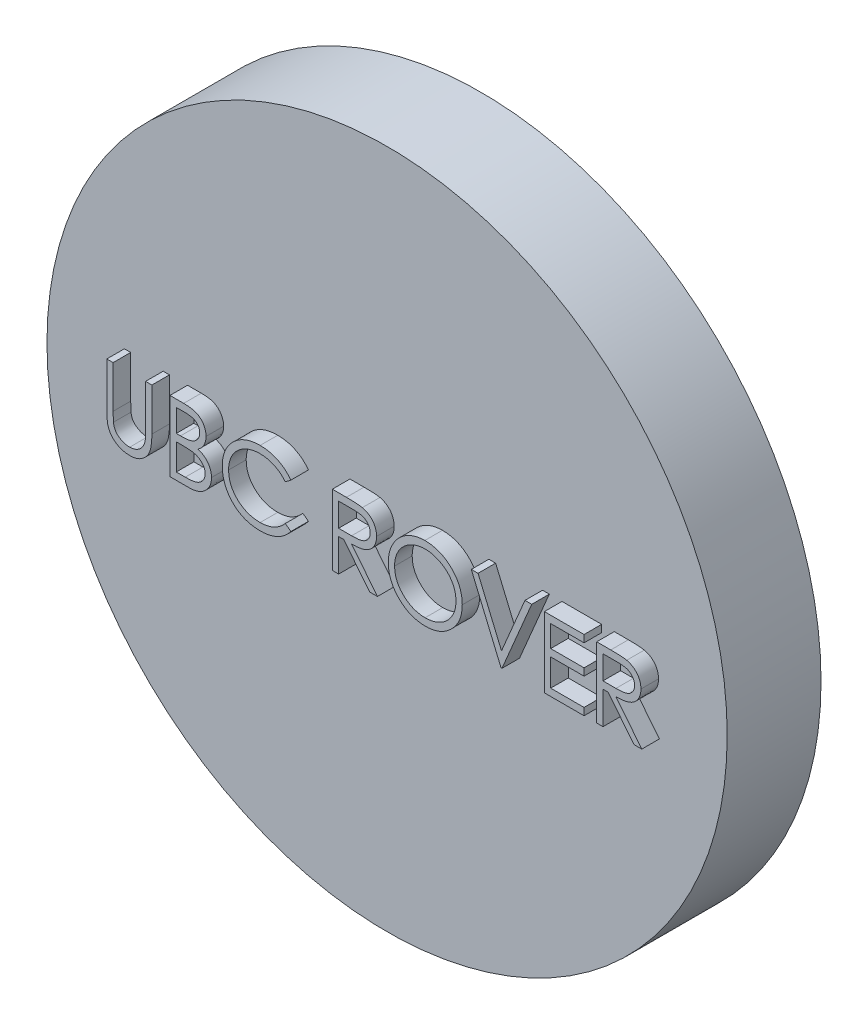
from build123d import *

# Parameters (mm, degrees)
SKETCH1_R           = 29
PLATE_DEPTH         = 8
BOSS_EXTRUDE4_DEPTH = 1.5


with BuildPart() as part:
    # Sketch1 → Plate (new body)
    with BuildSketch(Plane.XY):
        Circle(SKETCH1_R)
    extrude(amount=PLATE_DEPTH)

    # Sketch4 → Boss-Extrude4 (add)
    with BuildSketch(Plane.XY.offset(8)):
        with BuildLine():
            Line((-22.398192779, 2.851925), (-21.85973124, 2.851925))
            Line((-21.85973124, 2.851925), (-21.85973124, -0.743026923))
            add(Edge.make_bspline(
                [(-21.85973124, -0.743026923), (-21.859811373, -0.793908184), (-21.859963438, -0.890464146), (-21.8589477, -1.027895518), (-21.856103068, -1.150076877), (-21.854309652, -1.257479187), (-21.850319937, -1.349609611), (-21.847066143, -1.426967286), (-21.842882331, -1.489185919), (-21.83785413, -1.525496078), (-21.835692779, -1.541103846)],
                knots=[0, 0, 0, 0, 0.000152644, 0.000289669, 0.000412288, 0.000519287, 0.000611905, 0.000688912, 0.000751597, 0.000798856, 0.000798856, 0.000798856, 0.000798856], degree=3))
            add(Edge.make_bspline(
                [(-21.835692779, -1.541103846), (-21.826817135, -1.597412583), (-21.809565958, -1.706857262), (-21.765600739, -1.862700031), (-21.704199309, -2.003153959), (-21.631439807, -2.132601887), (-21.535555331, -2.24744079), (-21.420692127, -2.353232195), (-21.281530238, -2.445755288), (-21.126797772, -2.53035668), (-20.960023079, -2.598353964), (-20.789603765, -2.64977116), (-20.618101515, -2.681106417), (-20.503285232, -2.684734769), (-20.446269702, -2.686536538)],
                knots=[0, 0, 0, 0, 0.000170931, 0.000332231, 0.000484054, 0.000630007, 0.000776055, 0.000930884, 0.001096906, 0.001275996, 0.001459245, 0.001636075, 0.001809373, 0.001980317, 0.001980317, 0.001980317, 0.001980317], degree=3))
            add(Edge.make_bspline(
                [(-20.446269702, -2.686536538), (-20.397320432, -2.684695652), (-20.299704612, -2.681024512), (-20.154665017, -2.658290631), (-20.013407687, -2.617318232), (-19.875235093, -2.564450075), (-19.74571912, -2.494597062), (-19.624787505, -2.413904194), (-19.516849332, -2.319256978), (-19.418349907, -2.21451353), (-19.332575732, -2.096331016), (-19.258225203, -1.967282779), (-19.197323609, -1.825426756), (-19.167248995, -1.725733461), (-19.151798548, -1.674517308)],
                knots=[0, 0, 0, 0, 0.000146876, 0.000292903, 0.000439015, 0.000587441, 0.000735844, 0.000879522, 0.001022667, 0.00116554, 0.001310021, 0.001459697, 0.001611521, 0.001771922, 0.001771922, 0.001771922, 0.001771922], degree=3))
            add(Edge.make_bspline(
                [(-19.151798548, -1.674517308), (-19.146655476, -1.653348323), (-19.135194639, -1.606175294), (-19.124485419, -1.526424511), (-19.113331375, -1.432328458), (-19.105592113, -1.323211065), (-19.098047163, -1.199437969), (-19.093533324, -1.060364385), (-19.091446982, -0.906495309), (-19.090825244, -0.799117317), (-19.090500471, -0.743026923)],
                knots=[0, 0, 0, 0, 6.5314e-05, 0.000145547, 0.000241113, 0.000349613, 0.00047362, 0.000613126, 0.000766991, 0.000935265, 0.000935265, 0.000935265, 0.000935265], degree=3))
            Line((-19.090500471, -0.743026923), (-19.090500471, 2.851925))
            Line((-19.090500471, 2.851925), (-18.552038932, 2.851925))
            Line((-18.552038932, 2.851925), (-18.552038932, -0.771873077))
            add(Edge.make_bspline(
                [(-18.552038932, -0.771873077), (-18.552474567, -0.837184584), (-18.553324735, -0.96464396), (-18.560697152, -1.151417718), (-18.572452009, -1.328594258), (-18.58906016, -1.496197395), (-18.611066451, -1.653627382), (-18.635538258, -1.802264127), (-18.666703172, -1.941040686), (-18.703103288, -2.071039117), (-18.744715085, -2.194785711), (-18.798614196, -2.31222905), (-18.85934191, -2.42693945), (-18.931367029, -2.537181922), (-19.012300828, -2.643444585), (-19.103932281, -2.745082999), (-19.203230842, -2.843721364), (-19.31184723, -2.936829477), (-19.427990988, -3.022215781), (-19.55131663, -3.097297674), (-19.680876806, -3.160766732), (-19.816334737, -3.213011174), (-19.957748228, -3.252293344), (-20.105120844, -3.28156504), (-20.258788033, -3.29819755), (-20.363298872, -3.30066943), (-20.416221625, -3.301921154)],
                knots=[0, 0, 0, 0, 0.000195928, 0.000382366, 0.000560656, 0.000728569, 0.0008875, 0.001037476, 0.001180358, 0.001313923, 0.001442399, 0.001571515, 0.001701111, 0.001831463, 0.001966084, 0.002101432, 0.002241667, 0.002385722, 0.002530203, 0.00267367, 0.002818266, 0.002962462, 0.003108574, 0.003258019, 0.003412782, 0.00357155, 0.00357155, 0.00357155, 0.00357155], degree=3))
            add(Edge.make_bspline(
                [(-20.416221625, -3.301921154), (-20.473940086, -3.300575842), (-20.587183502, -3.297936345), (-20.75404876, -3.28281163), (-20.914015953, -3.254322954), (-21.0687746, -3.218048765), (-21.216217738, -3.168019501), (-21.358320785, -3.109565573), (-21.492649953, -3.037775984), (-21.621384459, -2.957901596), (-21.741084041, -2.868030788), (-21.850965304, -2.770076204), (-21.951209653, -2.665606985), (-22.040127418, -2.553492072), (-22.119191792, -2.434603432), (-22.187300729, -2.308604735), (-22.245780576, -2.175544765), (-22.275963263, -2.083053564), (-22.291221625, -2.036296154)],
                knots=[0, 0, 0, 0, 0.000173181, 0.000339781, 0.000502009, 0.000660303, 0.000816137, 0.000968596, 0.001120747, 0.001272485, 0.001422726, 0.001569153, 0.001713674, 0.001856521, 0.001997863, 0.002141462, 0.002285712, 0.002433192, 0.002433192, 0.002433192, 0.002433192], degree=3))
            add(Edge.make_bspline(
                [(-22.291221625, -2.036296154), (-22.300096753, -2.004354598), (-22.319347104, -1.935072651), (-22.3399619, -1.820410099), (-22.357291754, -1.688384526), (-22.373586997, -1.538986894), (-22.383202353, -1.372101409), (-22.391632248, -1.18780041), (-22.398252166, -0.985861047), (-22.398213128, -0.845196163), (-22.398192779, -0.771873077)],
                knots=[0, 0, 0, 0, 9.9411e-05, 0.000215626, 0.000349061, 0.000498916, 0.000666333, 0.00085042, 0.001052432, 0.001272388, 0.001272388, 0.001272388, 0.001272388], degree=3))
            Line((-22.398192779, -0.771873077), (-22.398192779, 2.851925))
        make_face()
        with BuildLine():
            Line((-17.013577394, 2.851925), (-15.842904317, 2.851925))
            add(Edge.make_bspline(
                [(-15.842904317, 2.851925), (-15.785598354, 2.851623714), (-15.674525137, 2.851039746), (-15.513006094, 2.841982949), (-15.361722418, 2.829633801), (-15.220630237, 2.810039356), (-15.089794747, 2.78639631), (-14.968821655, 2.757764625), (-14.858095645, 2.723433287), (-14.725902383, 2.668839662), (-14.57518125, 2.587714231), (-14.411984005, 2.467836691), (-14.272433881, 2.321209611), (-14.15211448, 2.155810773), (-14.056455417, 1.973863736), (-13.987250908, 1.779705127), (-13.943437407, 1.575839283), (-13.93893152, 1.43587955), (-13.936654317, 1.365146154)],
                knots=[0, 0, 0, 0, 0.000171892, 0.000333169, 0.000485187, 0.000627121, 0.000760318, 0.000883923, 0.000999864, 0.001107669, 0.001312564, 0.001511844, 0.001712447, 0.001917282, 0.002123733, 0.002326748, 0.002534183, 0.002746134, 0.002746134, 0.002746134, 0.002746134], degree=3))
            add(Edge.make_bspline(
                [(-13.936654317, 1.365146154), (-13.938528406, 1.29888463), (-13.942211167, 1.168674486), (-13.977427326, 0.978227442), (-14.0325599, 0.796939638), (-14.10919747, 0.625472692), (-14.208800892, 0.467700783), (-14.326843724, 0.322351185), (-14.4692611, 0.195577944), (-14.575963797, 0.124704397), (-14.630163932, 0.088703846)],
                knots=[0, 0, 0, 0, 0.000198612, 0.000390292, 0.000578867, 0.000766074, 0.000951829, 0.001137116, 0.001326066, 0.001521126, 0.001521126, 0.001521126, 0.001521126], degree=3))
            add(Edge.make_bspline(
                [(-14.630163932, 0.088703846), (-14.562003199, 0.062535277), (-14.431594833, 0.01246832), (-14.252133097, -0.076049618), (-14.097513363, -0.172327521), (-13.966546827, -0.277467836), (-13.854539418, -0.390797226), (-13.756734376, -0.513977422), (-13.673280591, -0.648615292), (-13.601772722, -0.793307067), (-13.545974855, -0.946575299), (-13.50418759, -1.106982343), (-13.480243392, -1.273953009), (-13.476836007, -1.387585088), (-13.475115856, -1.44495)],
                knots=[0, 0, 0, 0, 0.000218951, 0.000418908, 0.000599313, 0.000764309, 0.000921541, 0.001076402, 0.001235147, 0.001395868, 0.001559758, 0.00172359, 0.001892378, 0.002064459, 0.002064459, 0.002064459, 0.002064459], degree=3))
            add(Edge.make_bspline(
                [(-13.475115856, -1.44495), (-13.476790449, -1.503521781), (-13.480085258, -1.6187634), (-13.504393781, -1.788057917), (-13.54555225, -1.94984354), (-13.602245644, -2.10516671), (-13.676238183, -2.25372694), (-13.766286122, -2.395692536), (-13.873654517, -2.529637103), (-13.993762292, -2.657049028), (-14.129640256, -2.771610949), (-14.276238693, -2.873637875), (-14.435403813, -2.95754541), (-14.604521517, -3.028030018), (-14.785488916, -3.08187093), (-14.977493385, -3.119538199), (-15.180369331, -3.144918263), (-15.319586048, -3.1470049), (-15.39098124, -3.148075)],
                knots=[0, 0, 0, 0, 0.000175682, 0.00034566, 0.000511821, 0.000675711, 0.000840729, 0.001008779, 0.001179033, 0.001355011, 0.001533224, 0.001711255, 0.001889776, 0.002071914, 0.002260141, 0.002455078, 0.002658427, 0.002872491, 0.002872491, 0.002872491, 0.002872491], degree=3))
            Line((-15.39098124, -3.148075), (-17.013577394, -3.148075))
            Line((-17.013577394, -3.148075), (-17.013577394, 2.851925))
        make_face()
        with BuildLine():
            Line((-16.475115856, 2.236540385), (-16.475115856, 0.313463462))
            Line((-16.475115856, 0.313463462), (-16.113337009, 0.313463462))
            add(Edge.make_bspline(
                [(-16.113337009, 0.313463462), (-16.06045336, 0.314149044), (-15.958271373, 0.315473729), (-15.810294407, 0.319268329), (-15.672937233, 0.329893547), (-15.546436948, 0.34051571), (-15.430992758, 0.357786432), (-15.326860424, 0.378344357), (-15.232405687, 0.40008648), (-15.123480752, 0.437062743), (-14.999927126, 0.491710186), (-14.868213233, 0.576519048), (-14.752096999, 0.677532225), (-14.654044677, 0.794088159), (-14.573796442, 0.922430192), (-14.518058645, 1.060510559), (-14.480263301, 1.204887928), (-14.476849247, 1.304004933), (-14.475115856, 1.354328846)],
                knots=[0, 0, 0, 0, 0.000158672, 0.000306587, 0.000443943, 0.000571912, 0.000687328, 0.000793873, 0.000890365, 0.000977783, 0.00113863, 0.001294329, 0.001445952, 0.001598616, 0.001749719, 0.001897926, 0.002043974, 0.002194603, 0.002194603, 0.002194603, 0.002194603], degree=3))
            add(Edge.make_bspline(
                [(-14.475115856, 1.354328846), (-14.476017879, 1.387630169), (-14.477787296, 1.452954349), (-14.492278672, 1.548181814), (-14.516908799, 1.637742532), (-14.54854473, 1.722863864), (-14.592753911, 1.800884179), (-14.644805562, 1.874501086), (-14.707695317, 1.941207575), (-14.779279282, 2.003555286), (-14.861579778, 2.05883162), (-14.954547707, 2.107244356), (-15.059440868, 2.146228545), (-15.174491476, 2.180370521), (-15.301470483, 2.204350453), (-15.438912575, 2.224327689), (-15.587943522, 2.234498104), (-15.691049412, 2.23584444), (-15.744346625, 2.236540385)],
                knots=[0, 0, 0, 0, 9.9875e-05, 0.000195916, 0.00028805, 0.000378226, 0.000467533, 0.000556256, 0.000648107, 0.000741841, 0.000840516, 0.000944807, 0.001055521, 0.001175713, 0.001304415, 0.001442777, 0.001592207, 0.001752104, 0.001752104, 0.001752104, 0.001752104], degree=3))
            Line((-15.744346625, 2.236540385), (-16.475115856, 2.236540385))
        make_face(mode=Mode.SUBTRACT)
        with BuildLine():
            Line((-16.475115856, -0.301921154), (-16.475115856, -2.532690385))
            Line((-16.475115856, -2.532690385), (-15.708288932, -2.532690385))
            add(Edge.make_bspline(
                [(-15.708288932, -2.532690385), (-15.653399345, -2.532032532), (-15.547606902, -2.530764608), (-15.394861936, -2.526625371), (-15.253290901, -2.517210041), (-15.123539811, -2.502388585), (-15.004207607, -2.486311243), (-14.89672583, -2.464691905), (-14.800223213, -2.439922258), (-14.688324399, -2.401635106), (-14.562318385, -2.342155441), (-14.426528346, -2.25247391), (-14.305797686, -2.145633954), (-14.203274384, -2.021980958), (-14.119252118, -1.887527255), (-14.058128481, -1.744992369), (-14.02042987, -1.596731465), (-14.015866151, -1.495645672), (-14.013577394, -1.44495)],
                knots=[0, 0, 0, 0, 0.000164681, 0.000317401, 0.000458354, 0.000590155, 0.00070914, 0.000819455, 0.000918867, 0.001007809, 0.001173944, 0.001335288, 0.001494492, 0.00165577, 0.001815535, 0.001968463, 0.002119466, 0.002271384, 0.002271384, 0.002271384, 0.002271384], degree=3))
            add(Edge.make_bspline(
                [(-14.013577394, -1.44495), (-14.014050716, -1.413247131), (-14.014989724, -1.350352762), (-14.029150779, -1.257925643), (-14.049745984, -1.168395575), (-14.076371299, -1.081519448), (-14.115147528, -0.998867946), (-14.160415891, -0.918806415), (-14.21349258, -0.841229022), (-14.296196864, -0.743150873), (-14.416491695, -0.63015028), (-14.587417596, -0.519514561), (-14.781770106, -0.430289749), (-14.922731523, -0.392404933), (-14.995548548, -0.372834615)],
                knots=[0, 0, 0, 0, 9.502e-05, 0.000188508, 0.000279767, 0.000370614, 0.000460437, 0.000553016, 0.000646365, 0.000741931, 0.000937523, 0.001138873, 0.001350251, 0.001576123, 0.001576123, 0.001576123, 0.001576123], degree=3))
            add(Edge.make_bspline(
                [(-14.995548548, -0.372834615), (-15.024741284, -0.366911614), (-15.088037156, -0.354069326), (-15.191250151, -0.340513263), (-15.309083069, -0.328436018), (-15.441808002, -0.319502605), (-15.589592872, -0.31026853), (-15.752753304, -0.306677408), (-15.930622986, -0.302392962), (-16.054038482, -0.302082446), (-16.118144702, -0.301921154)],
                knots=[0, 0, 0, 0, 8.9339e-05, 0.000193706, 0.000312106, 0.000444667, 0.000592743, 0.000756275, 0.000934196, 0.001126508, 0.001126508, 0.001126508, 0.001126508], degree=3))
            Line((-16.118144702, -0.301921154), (-16.475115856, -0.301921154))
        make_face(mode=Mode.SUBTRACT)
        with BuildLine():
            Line((-6.705885086, 1.750963462), (-7.177038932, 1.390386538))
            add(Edge.make_bspline(
                [(-7.177038932, 1.390386538), (-7.210649027, 1.430442487), (-7.277416078, 1.510014342), (-7.384831854, 1.621750704), (-7.496777528, 1.72643401), (-7.613210307, 1.824562946), (-7.73622594, 1.912705973), (-7.862844452, 1.995456435), (-7.995183958, 2.0696297), (-8.178186932, 2.159566248), (-8.417583243, 2.253416799), (-8.718945825, 2.332108053), (-9.033536279, 2.382201497), (-9.248160736, 2.38762694), (-9.357327394, 2.390386538)],
                knots=[0, 0, 0, 0, 0.000156831, 0.000311548, 0.000464613, 0.000616503, 0.000767965, 0.00091832, 0.001070087, 0.001222745, 0.001529866, 0.00183948, 0.002155656, 0.002482953, 0.002482953, 0.002482953, 0.002482953], degree=3))
            add(Edge.make_bspline(
                [(-9.357327394, 2.390386538), (-9.417470193, 2.389694031), (-9.537197609, 2.388315444), (-9.714880706, 2.370128372), (-9.889245937, 2.344566298), (-10.060179879, 2.306637172), (-10.227464951, 2.258684111), (-10.392194783, 2.201383402), (-10.551984382, 2.13048939), (-10.709044219, 2.052132373), (-10.859522867, 1.963628182), (-11.001902949, 1.867091008), (-11.135665179, 1.763601128), (-11.260915371, 1.65277066), (-11.377781569, 1.535098728), (-11.485416959, 1.409331285), (-11.58344909, 1.275870416), (-11.673821133, 1.136476003), (-11.754757248, 0.991554075), (-11.822522755, 0.84056824), (-11.882531536, 0.686104063), (-11.930015952, 0.526416359), (-11.967600838, 0.36262876), (-11.993533975, 0.194301695), (-12.011514212, 0.021786816), (-12.012885943, -0.095143434), (-12.013577394, -0.154084615)],
                knots=[0, 0, 0, 0, 0.000180353, 0.000359031, 0.000535305, 0.000708823, 0.000883826, 0.00105717, 0.001231565, 0.001407871, 0.0015835, 0.001754849, 0.001923619, 0.002090509, 0.00225624, 0.002420763, 0.002586632, 0.002752659, 0.002918898, 0.003084022, 0.003248755, 0.003415684, 0.003583339, 0.003752485, 0.003926378, 0.004103127, 0.004103127, 0.004103127, 0.004103127], degree=3))
            add(Edge.make_bspline(
                [(-12.013577394, -0.154084615), (-12.011414276, -0.242766878), (-12.00716728, -0.416882738), (-11.969370136, -0.67191807), (-11.911932836, -0.916239225), (-11.82584899, -1.148318955), (-11.719702046, -1.371018997), (-11.585575284, -1.580571317), (-11.430232648, -1.780142571), (-11.251476501, -1.965016196), (-11.055352245, -2.133896868), (-10.844927253, -2.28261215), (-10.620725617, -2.40658052), (-10.385222822, -2.509739286), (-10.136606627, -2.589036533), (-9.875324109, -2.644860745), (-9.601943545, -2.681275911), (-9.41513886, -2.684762234), (-9.320067779, -2.686536538)],
                knots=[0, 0, 0, 0, 0.000265897, 0.000522053, 0.000771883, 0.00101751, 0.001263177, 0.001510598, 0.001762331, 0.002020747, 0.002280699, 0.002537793, 0.002792288, 0.003047962, 0.003307955, 0.003573646, 0.0038487, 0.004133761, 0.004133761, 0.004133761, 0.004133761], degree=3))
            add(Edge.make_bspline(
                [(-9.320067779, -2.686536538), (-9.215320312, -2.683641487), (-9.009152239, -2.677943335), (-8.706807051, -2.629670336), (-8.41737431, -2.55139962), (-8.140838448, -2.441860324), (-7.877979054, -2.299462688), (-7.628384779, -2.126837755), (-7.391844944, -1.922343471), (-7.24960846, -1.766200965), (-7.177038932, -1.686536538)],
                knots=[0, 0, 0, 0, 0.000314091, 0.000618206, 0.0009159, 0.001212076, 0.001508388, 0.001810781, 0.002120928, 0.002443998, 0.002443998, 0.002443998, 0.002443998], degree=3))
            Line((-7.177038932, -1.686536538), (-6.705885086, -2.043507692))
            add(Edge.make_bspline(
                [(-6.705885086, -2.043507692), (-6.743801846, -2.092430753), (-6.819453747, -2.190042535), (-6.941953204, -2.32765118), (-7.071, -2.45708667), (-7.207552646, -2.577305449), (-7.350040288, -2.690713104), (-7.501021395, -2.794087672), (-7.658511165, -2.888872045), (-7.821975986, -2.975661059), (-7.991242179, -3.052662053), (-8.166106925, -3.118582798), (-8.345816483, -3.175368323), (-8.530379069, -3.222085929), (-8.720177509, -3.258550644), (-8.914526893, -3.28292723), (-9.113846679, -3.299627654), (-9.248317687, -3.301149796), (-9.316462009, -3.301921154)],
                knots=[0, 0, 0, 0, 0.000185646, 0.000370402, 0.000552278, 0.000733641, 0.00091591, 0.001098274, 0.00128214, 0.001467096, 0.001653208, 0.001839603, 0.002027388, 0.002218327, 0.002410443, 0.002606784, 0.002805716, 0.003010099, 0.003010099, 0.003010099, 0.003010099], degree=3))
            add(Edge.make_bspline(
                [(-9.316462009, -3.301921154), (-9.38099401, -3.301472024), (-9.50859805, -3.300583925), (-9.69699591, -3.286197352), (-9.88040662, -3.266569231), (-10.058305979, -3.237014721), (-10.231664793, -3.20213871), (-10.398911509, -3.155387984), (-10.56169187, -3.103017984), (-10.719351883, -3.041466578), (-10.872025654, -2.972010265), (-11.019220759, -2.89351045), (-11.1608695, -2.806627253), (-11.298364507, -2.713275807), (-11.429674651, -2.610457575), (-11.555937837, -2.499600488), (-11.677862082, -2.381078183), (-11.753295256, -2.29561272), (-11.791221625, -2.252642308)],
                knots=[0, 0, 0, 0, 0.000193543, 0.000382708, 0.000566539, 0.000746747, 0.00092354, 0.001096738, 0.001267399, 0.001436362, 0.001604171, 0.001770319, 0.001936463, 0.002102485, 0.002268621, 0.002436413, 0.002606399, 0.002778286, 0.002778286, 0.002778286, 0.002778286], degree=3))
            add(Edge.make_bspline(
                [(-11.791221625, -2.252642308), (-11.851968442, -2.17800027), (-11.972728688, -2.029617337), (-12.12722986, -1.789127084), (-12.259482812, -1.538038726), (-12.366412962, -1.275033134), (-12.450006219, -1.00070047), (-12.507916839, -0.714902445), (-12.545548161, -0.417905973), (-12.549851513, -0.215900049), (-12.552038932, -0.113219231)],
                knots=[0, 0, 0, 0, 0.000288524, 0.000573565, 0.000855812, 0.001138826, 0.001423989, 0.001714869, 0.002012732, 0.002320659, 0.002320659, 0.002320659, 0.002320659], degree=3))
            add(Edge.make_bspline(
                [(-12.552038932, -0.113219231), (-12.549372886, -0.005295596), (-12.544127607, 0.207037417), (-12.499563386, 0.518649909), (-12.427874021, 0.817195164), (-12.326050784, 1.102115869), (-12.196955896, 1.374910635), (-12.037481701, 1.633495558), (-11.849480885, 1.879524357), (-11.634427912, 2.109263931), (-11.398598195, 2.319331392), (-11.146051657, 2.504142027), (-10.877282605, 2.657943483), (-10.595252002, 2.786508333), (-10.297847976, 2.885327413), (-9.985705058, 2.954504304), (-9.659409775, 2.997562218), (-9.436788474, 3.003005432), (-9.323673548, 3.005771154)],
                knots=[0, 0, 0, 0, 0.000323639, 0.000636739, 0.000942248, 0.001243334, 0.001542789, 0.001846019, 0.002153001, 0.002470202, 0.00278861, 0.00309922, 0.003407222, 0.003715983, 0.00402765, 0.004345485, 0.004673912, 0.005013161, 0.005013161, 0.005013161, 0.005013161], degree=3))
            add(Edge.make_bspline(
                [(-9.323673548, 3.005771154), (-9.254734453, 3.004944631), (-9.118276458, 3.003308613), (-8.916414768, 2.987355226), (-8.719885065, 2.960760473), (-8.528551952, 2.924561496), (-8.34148461, 2.879634659), (-8.160112769, 2.821108434), (-7.983372163, 2.754188666), (-7.812377463, 2.67711701), (-7.647949091, 2.590602596), (-7.49013826, 2.495604384), (-7.340198502, 2.392240146), (-7.197074762, 2.281388988), (-7.063161257, 2.160705744), (-6.934655865, 2.033509865), (-6.815922588, 1.896137595), (-6.742631397, 1.799443423), (-6.705885086, 1.750963462)],
                knots=[0, 0, 0, 0, 0.000206787, 0.000409313, 0.000607003, 0.000801481, 0.000993296, 0.001183735, 0.001372804, 0.001560011, 0.00174603, 0.001929897, 0.002112261, 0.0022921, 0.002472565, 0.002652741, 0.002834215, 0.00301669, 0.00301669, 0.00301669, 0.00301669], degree=3))
        make_face()
        with BuildLine():
            Line((-3.167423548, 2.851925), (-1.966702394, 2.851925))
            add(Edge.make_bspline(
                [(-1.966702394, 2.851925), (-1.886574745, 2.851658281), (-1.732720783, 2.851146151), (-1.512309463, 2.848290558), (-1.312034439, 2.840105948), (-1.132000429, 2.833062662), (-0.972210735, 2.820219334), (-0.832175379, 2.807943939), (-0.712539326, 2.791874806), (-0.640117867, 2.776951224), (-0.607327394, 2.770194231)],
                knots=[0, 0, 0, 0, 0.000240388, 0.000461571, 0.00066122, 0.000841705, 0.001002012, 0.001142061, 0.001263425, 0.001363841, 0.001363841, 0.001363841, 0.001363841], degree=3))
            add(Edge.make_bspline(
                [(-0.607327394, 2.770194231), (-0.563430324, 2.759348347), (-0.476572628, 2.737887952), (-0.351515372, 2.692528637), (-0.232347959, 2.640037852), (-0.119565403, 2.57838576), (-0.013732618, 2.507114709), (0.086241629, 2.42745507), (0.180810994, 2.339842718), (0.266150932, 2.242068704), (0.346617878, 2.13949183), (0.414484095, 2.028571104), (0.472986631, 1.912579914), (0.51956466, 1.790338626), (0.557069758, 1.663032732), (0.58351474, 1.52950908), (0.599373918, 1.39037598), (0.600988528, 1.295476708), (0.601807221, 1.247357692)],
                knots=[0, 0, 0, 0, 0.000135567, 0.000268242, 0.000398455, 0.000525939, 0.00065328, 0.000780735, 0.000909138, 0.001039396, 0.001169693, 0.001299773, 0.001428776, 0.001558907, 0.001691647, 0.001826477, 0.001966773, 0.002111084, 0.002111084, 0.002111084, 0.002111084], degree=3))
            add(Edge.make_bspline(
                [(0.601807221, 1.247357692), (0.599288939, 1.167411799), (0.594375118, 1.011416654), (0.548560654, 0.785026571), (0.473515192, 0.573844889), (0.370103839, 0.37813751), (0.238413309, 0.201719261), (0.080142239, 0.046764194), (-0.104797667, -0.082904227), (-0.276962208, -0.172823321), (-0.429043693, -0.230411164), (-0.554243658, -0.270930637), (-0.69081562, -0.302236863), (-0.83745105, -0.330282803), (-0.994760174, -0.351457136), (-1.162365956, -0.366965584), (-1.34038793, -0.376658239), (-1.462683477, -0.378101676), (-1.525596625, -0.378844231)],
                knots=[0, 0, 0, 0, 0.000239617, 0.000467555, 0.00068957, 0.000910017, 0.001129008, 0.001347444, 0.001571557, 0.001804323, 0.001927981, 0.002059123, 0.002198764, 0.002347981, 0.002506913, 0.002674709, 0.002852853, 0.00304159, 0.00304159, 0.00304159, 0.00304159], degree=3))
            Line((-1.525596625, -0.378844231), (0.678730298, -3.148075))
            Line((0.678730298, -3.148075), (0.012864914, -3.148075))
            Line((0.012864914, -3.148075), (-2.191462009, -0.378844231))
            Line((-2.191462009, -0.378844231), (-2.628962009, -0.378844231))
            Line((-2.628962009, -0.378844231), (-2.628962009, -3.148075))
            Line((-2.628962009, -3.148075), (-3.167423548, -3.148075))
            Line((-3.167423548, -3.148075), (-3.167423548, 2.851925))
        make_face()
        with BuildLine():
            Line((-2.628962009, 2.236540385), (-2.628962009, 0.236540385))
            Line((-2.628962009, 0.236540385), (-1.530404317, 0.228126923))
            add(Edge.make_bspline(
                [(-1.530404317, 0.228126923), (-1.479112822, 0.228104232), (-1.379695295, 0.228060249), (-1.235865584, 0.234906723), (-1.101945393, 0.242695268), (-0.97844696, 0.254608432), (-0.865315117, 0.269961698), (-0.762606409, 0.289166814), (-0.670153177, 0.311541778), (-0.562327111, 0.346173137), (-0.441921629, 0.401040597), (-0.311067697, 0.480867166), (-0.199635118, 0.58127137), (-0.105490212, 0.696083009), (-0.029839758, 0.822316579), (0.023495193, 0.958458926), (0.057339379, 1.101073094), (0.061331172, 1.199092707), (0.063345683, 1.248559615)],
                knots=[0, 0, 0, 0, 0.000153851, 0.000298207, 0.000431885, 0.000556265, 0.000670322, 0.000774279, 0.000869603, 0.000955505, 0.001113666, 0.001265404, 0.001413529, 0.001561267, 0.001709475, 0.001852988, 0.00199848, 0.002146712, 0.002146712, 0.002146712, 0.002146712], degree=3))
            add(Edge.make_bspline(
                [(0.063345683, 1.248559615), (0.061284904, 1.296810885), (0.057201192, 1.392427294), (0.023860446, 1.532408854), (-0.032521351, 1.664523626), (-0.10850233, 1.788234172), (-0.20107231, 1.900529719), (-0.309617132, 1.996610553), (-0.431168895, 2.075895349), (-0.544776663, 2.126560002), (-0.646321028, 2.157622607), (-0.734486159, 2.179481745), (-0.834105835, 2.197043692), (-0.945663764, 2.211114653), (-1.068683703, 2.223208843), (-1.203787676, 2.23135475), (-1.350079299, 2.236178517), (-1.451474039, 2.236416955), (-1.503962009, 2.236540385)],
                knots=[0, 0, 0, 0, 0.000144636, 0.000286615, 0.000428814, 0.000573933, 0.000720745, 0.000863779, 0.001007131, 0.001154551, 0.001235143, 0.001325511, 0.001426887, 0.0015384, 0.001662781, 0.001797659, 0.001944372, 0.002101829, 0.002101829, 0.002101829, 0.002101829], degree=3))
            Line((-1.503962009, 2.236540385), (-2.628962009, 2.236540385))
        make_face(mode=Mode.SUBTRACT)
        with BuildLine():
            add(Edge.make_bspline(
                [(4.717191837, 3.005771154), (4.828291447, 3.002957189), (5.046500247, 2.997430331), (5.367200072, 2.955123296), (5.673363093, 2.881931199), (5.967483331, 2.7844518), (6.246042719, 2.654415711), (6.511137963, 2.497241171), (6.762138318, 2.311281527), (6.995660687, 2.097974281), (7.209358316, 1.86588836), (7.397631264, 1.618211943), (7.555418053, 1.356442568), (7.684993688, 1.081366858), (7.786648447, 0.793606913), (7.856795379, 0.491628623), (7.901603637, 0.177388582), (7.906842112, -0.036943186), (7.909499529, -0.145671154)],
                knots=[0, 0, 0, 0, 0.000333245, 0.000654521, 0.000968211, 0.001276459, 0.001582442, 0.001888546, 0.00219961, 0.002517836, 0.002835985, 0.003144881, 0.00344954, 0.003751167, 0.004055653, 0.004363218, 0.00467989, 0.00500593, 0.00500593, 0.00500593, 0.00500593], degree=3))
            add(Edge.make_bspline(
                [(7.909499529, -0.145671154), (7.906842502, -0.253598205), (7.901605193, -0.466334925), (7.856744432, -0.77858083), (7.786388432, -1.078736309), (7.68593769, -1.366300286), (7.556979727, -1.641576109), (7.398142291, -1.903839459), (7.211043072, -2.153176313), (6.998117042, -2.386855168), (6.76600097, -2.601136546), (6.517034798, -2.787854619), (6.256817678, -2.948524547), (5.982001036, -3.076725131), (5.696229544, -3.17919128), (5.396945562, -3.249052931), (5.085551469, -3.294116434), (4.873201177, -3.299291033), (4.76526876, -3.301921154)],
                knots=[0, 0, 0, 0, 0.000323639, 0.00063793, 0.000944326, 0.00124728, 0.001549995, 0.001854653, 0.002165471, 0.002483697, 0.002801845, 0.003111702, 0.003415957, 0.003717584, 0.004019803, 0.00432503, 0.00463813, 0.004961769, 0.004961769, 0.004961769, 0.004961769], degree=3))
            add(Edge.make_bspline(
                [(4.76526876, -3.301921154), (4.656541356, -3.299265062), (4.4422107, -3.294029198), (4.127575782, -3.24914679), (3.825385364, -3.178961698), (3.536503619, -3.078659807), (3.260769454, -2.949030269), (2.997643598, -2.790965619), (2.748182203, -2.60341052), (2.514453495, -2.390553535), (2.300597726, -2.158830874), (2.114153082, -1.91054358), (1.956052888, -1.650562797), (1.826858604, -1.378167041), (1.724576673, -1.094673139), (1.654796985, -0.798190035), (1.609649639, -0.490408025), (1.604447045, -0.280848771), (1.601807221, -0.174517308)],
                knots=[0, 0, 0, 0, 0.00032604, 0.000642712, 0.000951447, 0.001255536, 0.001558252, 0.00186394, 0.002174757, 0.002492983, 0.002811132, 0.003119305, 0.003422935, 0.00372239, 0.004022344, 0.004325233, 0.004634763, 0.004953599, 0.004953599, 0.004953599, 0.004953599], degree=3))
            add(Edge.make_bspline(
                [(1.601807221, -0.174517308), (1.602723739, -0.103147018), (1.604545213, 0.038693194), (1.626473829, 0.249321651), (1.658293888, 0.456562779), (1.703897167, 0.659827261), (1.763540024, 0.858617521), (1.833914928, 1.054304543), (1.919868949, 1.244905212), (2.017035774, 1.431322455), (2.125484588, 1.610650293), (2.245271587, 1.78015815), (2.372189362, 1.941268431), (2.511326608, 2.089806151), (2.658097657, 2.230092419), (2.814883448, 2.359971363), (2.980727295, 2.480614136), (3.156342803, 2.589334721), (3.337402703, 2.687664666), (3.524048608, 2.772044982), (3.713745588, 2.844466801), (3.907382127, 2.903165359), (4.104444022, 2.949505992), (4.305361367, 2.981061456), (4.509974098, 3.003046001), (4.647822073, 3.004858861), (4.717191837, 3.005771154)],
                knots=[0, 0, 0, 0, 0.000214027, 0.000425353, 0.000634616, 0.000842812, 0.00104969, 0.001256913, 0.001466206, 0.001676409, 0.00188728, 0.002094353, 0.002298768, 0.002502035, 0.002704373, 0.002907509, 0.003112344, 0.00331912, 0.003526702, 0.003730022, 0.003933158, 0.004135431, 0.004336598, 0.004539926, 0.004745272, 0.004953291, 0.004953291, 0.004953291, 0.004953291], degree=3))
        make_face()
        with BuildLine():
            add(Edge.make_bspline(
                [(4.743634144, 2.390386538), (4.686694773, 2.389692441), (4.573360373, 2.388310881), (4.404872597, 2.370112512), (4.23860071, 2.344175559), (4.074510375, 2.307178667), (3.913288165, 2.256771719), (3.753431294, 2.198758733), (3.596397488, 2.128094007), (3.44270516, 2.048255085), (3.293707888, 1.959885506), (3.153114686, 1.86221962), (3.020561582, 1.757547813), (2.896373125, 1.645625806), (2.780913972, 1.525883631), (2.671911627, 1.400136598), (2.573735201, 1.264790499), (2.483759927, 1.123515516), (2.403243629, 0.976495662), (2.331645878, 0.825278756), (2.273079006, 0.668631293), (2.225314932, 0.508252737), (2.185715257, 0.344397092), (2.16062853, 0.175821351), (2.142230199, 0.003372587), (2.140927607, -0.113167734), (2.14026876, -0.172113462)],
                knots=[0, 0, 0, 0, 0.000170741, 0.000339849, 0.000507809, 0.000675463, 0.000843891, 0.001014251, 0.001185347, 0.00136006, 0.001533621, 0.001704657, 0.001873222, 0.002040017, 0.002205765, 0.002371983, 0.002538821, 0.002706871, 0.002874163, 0.003041386, 0.003208366, 0.003375295, 0.003543221, 0.003713555, 0.003886252, 0.004063, 0.004063, 0.004063, 0.004063], degree=3))
            add(Edge.make_bspline(
                [(2.14026876, -0.172113462), (2.142454237, -0.258791554), (2.146753748, -0.429314178), (2.184395297, -0.679202424), (2.242375825, -0.919353772), (2.327845596, -1.148454188), (2.434732364, -1.368472959), (2.566778461, -1.577458281), (2.723222608, -1.775466637), (2.900931511, -1.96111567), (3.095199008, -2.13056562), (3.301483687, -2.279302892), (3.517575586, -2.405149034), (3.744038219, -2.507672016), (3.979662572, -2.588911566), (4.225966945, -2.644589219), (4.48131059, -2.681232857), (4.655363142, -2.684751867), (4.743634144, -2.686536538)],
                knots=[0, 0, 0, 0, 0.000259893, 0.000511291, 0.000756451, 0.000999822, 0.001243326, 0.001489089, 0.001739877, 0.001999161, 0.00225899, 0.002512166, 0.002760987, 0.003007876, 0.003256837, 0.003507281, 0.003764462, 0.004029106, 0.004029106, 0.004029106, 0.004029106], degree=3))
            add(Edge.make_bspline(
                [(4.743634144, -2.686536538), (4.802964719, -2.685721388), (4.920635067, -2.6841047), (5.095655962, -2.667821254), (5.267523754, -2.641709478), (5.435997376, -2.604114068), (5.600885624, -2.557061715), (5.762876716, -2.501162752), (5.920245213, -2.431423546), (6.074976364, -2.354369915), (6.223084207, -2.266529645), (6.364470833, -2.172178531), (6.495572513, -2.067660895), (6.619668064, -1.957401788), (6.735601245, -1.839178049), (6.842588075, -1.713143383), (6.940268302, -1.578502256), (7.03020941, -1.437441561), (7.110443575, -1.290019413), (7.180350602, -1.138254251), (7.239658229, -0.982519778), (7.287535666, -0.82259137), (7.3250536, -0.658772772), (7.350904892, -0.490844638), (7.368987929, -0.319142908), (7.370350919, -0.203010583), (7.371037991, -0.144469231)],
                knots=[0, 0, 0, 0, 0.00017795, 0.000352927, 0.000526825, 0.00069917, 0.000870375, 0.001041052, 0.001212763, 0.001386382, 0.00155933, 0.001729009, 0.001895886, 0.002061878, 0.002226765, 0.002392203, 0.002557362, 0.002725412, 0.002893758, 0.003060475, 0.003226332, 0.00339326, 0.003560915, 0.003730062, 0.003902758, 0.004078305, 0.004078305, 0.004078305, 0.004078305], degree=3))
            add(Edge.make_bspline(
                [(7.371037991, -0.144469231), (7.370350368, -0.086328366), (7.368986343, 0.029004748), (7.350913529, 0.199509008), (7.325026289, 0.366228799), (7.287718789, 0.528509605), (7.239632811, 0.68639279), (7.180340245, 0.839730072), (7.110422589, 0.989092692), (7.030179918, 1.134111487), (6.939981364, 1.273268181), (6.841419804, 1.406300888), (6.732793493, 1.530711302), (6.617206022, 1.649570777), (6.491770218, 1.760344302), (6.357054285, 1.863068623), (6.214693695, 1.960222808), (6.063961291, 2.047866628), (5.908400228, 2.128805313), (5.7487763, 2.19814989), (5.586897843, 2.257073523), (5.423176508, 2.307331177), (5.256234259, 2.344030658), (5.087199124, 2.370135886), (4.916304967, 2.388304547), (4.801373733, 2.389690339), (4.743634144, 2.390386538)],
                knots=[0, 0, 0, 0, 0.000174345, 0.000345846, 0.000513806, 0.000680288, 0.000844917, 0.001008528, 0.001173064, 0.001339304, 0.00150533, 0.001670235, 0.001835542, 0.002000429, 0.002167319, 0.002337041, 0.00250839, 0.002684019, 0.0028598, 0.003034195, 0.003205683, 0.003376411, 0.003547583, 0.003717917, 0.003889417, 0.004062561, 0.004062561, 0.004062561, 0.004062561], degree=3))
        make_face(mode=Mode.SUBTRACT)
        Polygon((8.678730298, 2.851925), (9.255653375, 2.851925), (11.255653375, -1.876440385), (13.255653375, 2.851925), (13.832576452, 2.851925), (11.294114914, -3.148075), (11.217191837, -3.148075), align=None)
        Polygon((14.909499529, 2.851925), (18.294114914, 2.851925), (18.294114914, 2.236540385), (15.447961068, 2.236540385), (15.447961068, 0.390386538), (18.294114914, 0.390386538), (18.294114914, -0.224998077), (15.447961068, -0.224998077), (15.447961068, -2.532690385), (18.294114914, -2.532690385), (18.294114914, -3.148075), (14.909499529, -3.148075), align=None)
        with BuildLine():
            Line((19.371037991, 2.851925), (20.571759144, 2.851925))
            add(Edge.make_bspline(
                [(20.571759144, 2.851925), (20.651886793, 2.851658281), (20.805740755, 2.851146151), (21.026152076, 2.848290558), (21.226427099, 2.840105948), (21.406461109, 2.833062662), (21.566250804, 2.820219334), (21.706286159, 2.807943939), (21.825922212, 2.791874806), (21.898343672, 2.776951224), (21.931134144, 2.770194231)],
                knots=[0, 0, 0, 0, 0.000240388, 0.000461571, 0.00066122, 0.000841705, 0.001002012, 0.001142061, 0.001263425, 0.001363841, 0.001363841, 0.001363841, 0.001363841], degree=3))
            add(Edge.make_bspline(
                [(21.931134144, 2.770194231), (21.975031214, 2.759348347), (22.061888911, 2.737887952), (22.186946167, 2.692528637), (22.306113579, 2.640037852), (22.418896135, 2.57838576), (22.52472892, 2.507114709), (22.624703167, 2.42745507), (22.719272533, 2.339842718), (22.80461247, 2.242068704), (22.885079416, 2.13949183), (22.952945633, 2.028571104), (23.01144817, 1.912579914), (23.058026199, 1.790338626), (23.095531296, 1.663032732), (23.121976278, 1.52950908), (23.137835457, 1.39037598), (23.139450066, 1.295476708), (23.14026876, 1.247357692)],
                knots=[0, 0, 0, 0, 0.000135567, 0.000268242, 0.000398455, 0.000525939, 0.00065328, 0.000780735, 0.000909138, 0.001039396, 0.001169693, 0.001299773, 0.001428776, 0.001558907, 0.001691647, 0.001826477, 0.001966773, 0.002111084, 0.002111084, 0.002111084, 0.002111084], degree=3))
            add(Edge.make_bspline(
                [(23.14026876, 1.247357692), (23.137750477, 1.167411799), (23.132836656, 1.011416654), (23.087022193, 0.785026571), (23.01197673, 0.573844889), (22.908565378, 0.37813751), (22.776874848, 0.201719261), (22.618603777, 0.046764194), (22.433663872, -0.082904227), (22.26149933, -0.172823321), (22.109417845, -0.230411164), (21.98421788, -0.270930637), (21.847645919, -0.302236863), (21.701010488, -0.330282803), (21.543701364, -0.351457136), (21.376095583, -0.366965584), (21.198073608, -0.376658239), (21.075778061, -0.378101676), (21.012864914, -0.378844231)],
                knots=[0, 0, 0, 0, 0.000239617, 0.000467555, 0.00068957, 0.000910017, 0.001129008, 0.001347444, 0.001571557, 0.001804323, 0.001927981, 0.002059123, 0.002198764, 0.002347981, 0.002506913, 0.002674709, 0.002852853, 0.00304159, 0.00304159, 0.00304159, 0.00304159], degree=3))
            Line((21.012864914, -0.378844231), (23.217191837, -3.148075))
            Line((23.217191837, -3.148075), (22.551326452, -3.148075))
            Line((22.551326452, -3.148075), (20.346999529, -0.378844231))
            Line((20.346999529, -0.378844231), (19.909499529, -0.378844231))
            Line((19.909499529, -0.378844231), (19.909499529, -3.148075))
            Line((19.909499529, -3.148075), (19.371037991, -3.148075))
            Line((19.371037991, -3.148075), (19.371037991, 2.851925))
        make_face()
        with BuildLine():
            Line((19.909499529, 2.236540385), (19.909499529, 0.236540385))
            Line((19.909499529, 0.236540385), (21.008057221, 0.228126923))
            add(Edge.make_bspline(
                [(21.008057221, 0.228126923), (21.059348717, 0.228104232), (21.158766243, 0.228060249), (21.302595954, 0.234906723), (21.436516146, 0.242695268), (21.560014578, 0.254608432), (21.673146421, 0.269961698), (21.77585513, 0.289166814), (21.868308362, 0.311541778), (21.976134428, 0.346173137), (22.09653991, 0.401040597), (22.227393841, 0.480867166), (22.33882642, 0.58127137), (22.432971327, 0.696083009), (22.508621781, 0.822316579), (22.561956731, 0.958458926), (22.595800918, 1.101073094), (22.59979271, 1.199092707), (22.601807221, 1.248559615)],
                knots=[0, 0, 0, 0, 0.000153851, 0.000298207, 0.000431885, 0.000556265, 0.000670322, 0.000774279, 0.000869603, 0.000955505, 0.001113666, 0.001265404, 0.001413529, 0.001561267, 0.001709475, 0.001852988, 0.00199848, 0.002146712, 0.002146712, 0.002146712, 0.002146712], degree=3))
            add(Edge.make_bspline(
                [(22.601807221, 1.248559615), (22.599746442, 1.296810885), (22.59566273, 1.392427294), (22.562321984, 1.532408854), (22.505940188, 1.664523626), (22.429959208, 1.788234172), (22.337389228, 1.900529719), (22.228844407, 1.996610553), (22.107292644, 2.075895349), (21.993684875, 2.126560002), (21.892140511, 2.157622607), (21.803975379, 2.179481745), (21.704355703, 2.197043692), (21.592797774, 2.211114653), (21.469777836, 2.223208843), (21.334673862, 2.23135475), (21.188382239, 2.236178517), (21.0869875, 2.236416955), (21.034499529, 2.236540385)],
                knots=[0, 0, 0, 0, 0.000144636, 0.000286615, 0.000428814, 0.000573933, 0.000720745, 0.000863779, 0.001007131, 0.001154551, 0.001235143, 0.001325511, 0.001426887, 0.0015384, 0.001662781, 0.001797659, 0.001944372, 0.002101829, 0.002101829, 0.002101829, 0.002101829], degree=3))
            Line((21.034499529, 2.236540385), (19.909499529, 2.236540385))
        make_face(mode=Mode.SUBTRACT)
    extrude(amount=BOSS_EXTRUDE4_DEPTH)


solid = part.part
